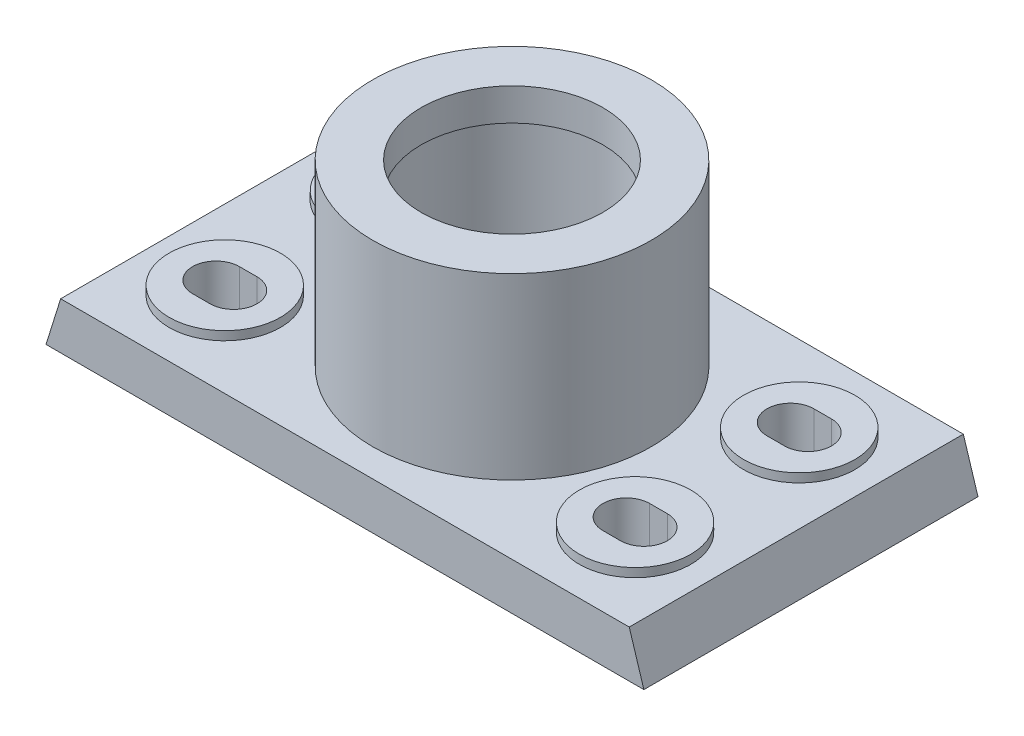
from build123d import *

# Parameters (mm, degrees)
BOSS_EXTRUDE1_DEPTH  = 57
SKETCH2_W            = 85.5
SKETCH2_H            = 94
CUT_EXTRUDE1_DEPTH   = 3
SKETCH4_R            = 47.5
BOSS_EXTRUDE2_DEPTH  = 61
SKETCH6_R            = 19
BOSS_EXTRUDE4_DEPTH  = 3
CUT_EXTRUDE2_DEPTH   = 20
MIRROR4_COPY_1_DEPTH = 20
SKETCH10_R           = 31
CUT_EXTRUDE3_DEPTH   = 11
SKETCH11_R           = 32.5
CUT_EXTRUDE4_DEPTH   = 37
SKETCH12_R           = 31
CUT_EXTRUDE5_DEPTH   = 13
SKETCH13_R           = 1.5
CUT_EXTRUDE6_DEPTH   = 5


with BuildPart() as part:
    # Sketch1 → Boss-Extrude1 (new body, symmetric)
    with BuildSketch(Plane.XY):
        Polygon((-102, 0), (102, 0), (97, 16), (-97, 16), align=None)
    extrude(amount=BOSS_EXTRUDE1_DEPTH, both=True)

    # Sketch2 → Cut-Extrude1 (cut)
    with BuildSketch(Plane.XZ):
        with Locations((-49.25, 0)):
            Rectangle(SKETCH2_W, SKETCH2_H)
    cut_extrude1 = extrude(amount=-CUT_EXTRUDE1_DEPTH, mode=Mode.SUBTRACT)

    # Mirror1: Cut-Extrude1 across plane
    add(cut_extrude1.mirror(Plane(origin=(0, 0, 0), x_dir=(0, 0, 1), z_dir=(1, 0, 0))), mode=Mode.SUBTRACT)

    # Sketch4 → Boss-Extrude2 (add)
    with BuildSketch(Plane(origin=(0, 16, 0), x_dir=(1, 0, 0), z_dir=(0, 1, 0))):
        with Locations(Location((0, 0, 0), (0, 0, 90))):  # turned: the seam where the file's is
            Circle(SKETCH4_R)
    extrude(amount=BOSS_EXTRUDE2_DEPTH)

    # Sketch6 → Boss-Extrude4 (add)
    with BuildSketch(Plane(origin=(0, 16, 0), x_dir=(1, 0, 0), z_dir=(0, 1, 0))):
        with Locations(Location((70, -28, 0), (0, 0, 90))):  # turned: the seam where the file's is
            Circle(SKETCH6_R)
        with Locations(Location((70, 28, 0), (0, 0, 90))):  # turned: the seam where the file's is
            Circle(SKETCH6_R)
    boss_extrude4 = extrude(amount=BOSS_EXTRUDE4_DEPTH)

    # Sketch9 → Cut-Extrude2 (cut, through all)
    with BuildSketch(Plane(origin=(0, 19, 0), x_dir=(1, 0, 0), z_dir=(0, 1, 0))):
        with BuildLine():
            Line((73, -36), (67, -36))
            ThreePointArc((67, -36), (59, -28), (67, -20))
            Line((67, -20), (73, -20))
            ThreePointArc((73, -20), (81, -28), (73, -36))
        make_face()
    cut_extrude2 = extrude(amount=-CUT_EXTRUDE2_DEPTH, mode=Mode.SUBTRACT)

    # Mirror2: Boss-Extrude4 across plane
    add(boss_extrude4.mirror(Plane(origin=(0, 0, 0), x_dir=(0, 0, 1), z_dir=(1, 0, 0))))

    # Mirror3: Cut-Extrude2 across plane
    add(cut_extrude2.mirror(Plane.XY), mode=Mode.SUBTRACT)

    # Mirror4: Cut-Extrude2 across plane
    add(cut_extrude2.mirror(Plane(origin=(0, 0, 0), x_dir=(0, 0, 1), z_dir=(1, 0, 0))), mode=Mode.SUBTRACT)

    # Mirror4 copy 1 sketch → Mirror4 copy 1 (cut, through all)
    with BuildSketch(Plane(origin=(0, 19, 0), x_dir=(-1, 0, 0), z_dir=(0, 1, 0))):
        with BuildLine():
            Line((73, -36), (67, -36))
            ThreePointArc((67, -36), (59, -28), (67, -20))
            Line((67, -20), (73, -20))
            ThreePointArc((73, -20), (81, -28), (73, -36))
        make_face()
    extrude(amount=-MIRROR4_COPY_1_DEPTH, mode=Mode.SUBTRACT)

    # Sketch10 → Cut-Extrude3 (cut)
    with BuildSketch(Plane(origin=(0, 77, 0), x_dir=(1, 0, 0), z_dir=(0, 1, 0))):
        with Locations(Location((0, 0, 0), (0, 0, 270))):  # turned: the seam where the file's is
            Circle(SKETCH10_R)
    extrude(amount=-CUT_EXTRUDE3_DEPTH, mode=Mode.SUBTRACT)

    # Sketch11 → Cut-Extrude4 (cut)
    with BuildSketch(Plane(origin=(0, 66, 0), x_dir=(1, 0, 0), z_dir=(0, 1, 0))):
        with Locations(Location((0, 0, 0), (0, 0, 270))):  # turned: the seam where the file's is
            Circle(SKETCH11_R)
    extrude(amount=-CUT_EXTRUDE4_DEPTH, mode=Mode.SUBTRACT)

    # Sketch12 → Cut-Extrude5 (cut)
    with BuildSketch(Plane(origin=(0, 29, 0), x_dir=(1, 0, 0), z_dir=(0, 1, 0))):
        with Locations(Location((0, 0, 0), (0, 0, 270))):  # turned: the seam where the file's is
            Circle(SKETCH12_R)
    extrude(amount=-CUT_EXTRUDE5_DEPTH, mode=Mode.SUBTRACT)

    # Sketch13 → Cut-Extrude6 (cut)
    with BuildSketch(Plane(origin=(0, 16, 0), x_dir=(1, 0, 0), z_dir=(0, 1, 0))):
        with Locations(Location((22, 0, 0), (0, 0, 270))):  # turned: the seam where the file's is
            Circle(SKETCH13_R)
    extrude(amount=-CUT_EXTRUDE6_DEPTH, mode=Mode.SUBTRACT)


solid = part.part
